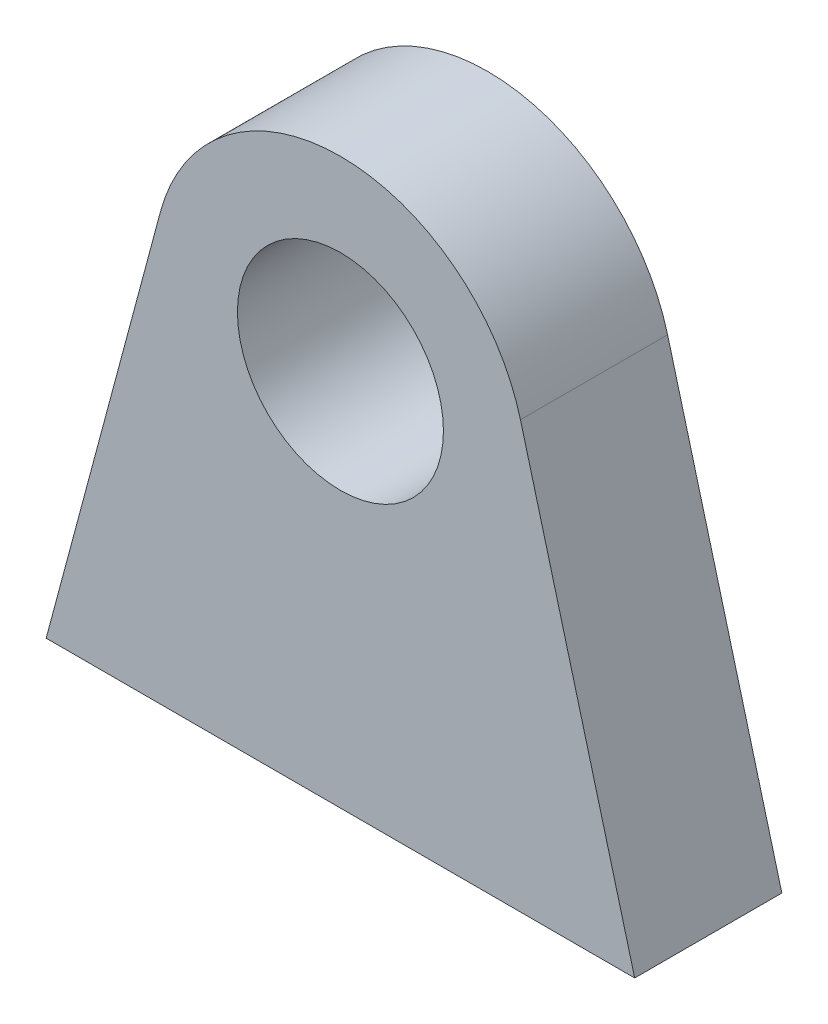
from build123d import *

# Parameters (mm, degrees)
EXTRUDE_1_DEPTH     = 10
SKETCH_2_R          = 7
CUT_EXTRUDE_1_DEPTH = 10


with BuildPart() as part:
    # 草图1 → 凸台-拉伸1 (new body)
    with BuildSketch(Plane.XY):
        with BuildLine():
            Line((-20, 0), (20, 0))
            Line((20, 0), (12.235428647, 28.977774789))
            ThreePointArc((12.235428647, 28.977774789), (0, 38.366349399), (-12.235428647, 28.977774789))
            Line((-12.235428647, 28.977774789), (-20, 0))
        make_face()
    extrude(amount=EXTRUDE_1_DEPTH)

    # 草图2 → 切除-拉伸1 (cut)
    with BuildSketch(Plane.XY):
        with Locations((0, 25.699301564)):
            Circle(SKETCH_2_R)
    extrude(amount=CUT_EXTRUDE_1_DEPTH, mode=Mode.SUBTRACT)


solid = part.part
